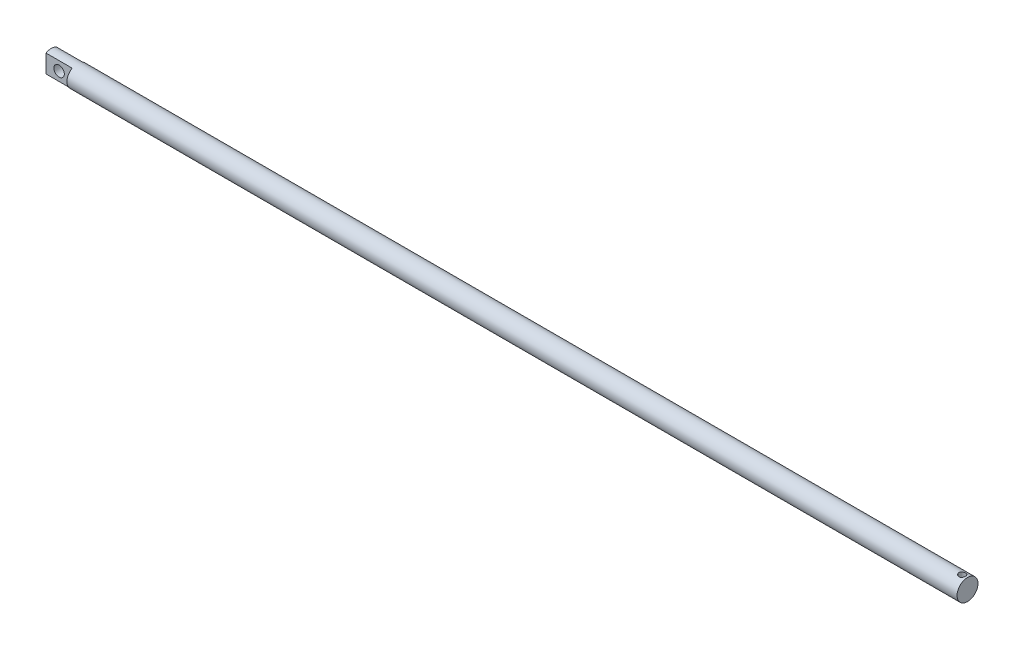
from build123d import *

# Parameters (mm, degrees)
SKETCH_1_R               = 8
EXTRUDE_1_DEPTH          = 700
SKETCH_2_R               = 4
CUT_EXTRUDE_1_DEPTH      = 9
CUT_EXTRUDE_1_DEPTH_BACK = 9
SKETCH_3_OUTSIDE_W       = 158.074
SKETCH_3_OUTSIDE_H       = 158.074
SKETCH_3_OUTSIDE_W_2     = 8
SKETCH_3_OUTSIDE_H_2     = 20
CUT_EXTRUDE_2_DEPTH      = 20
SKETCH_4_R               = 2.5
CUT_EXTRUDE_3_DEPTH      = 10


with BuildPart() as part:
    # 草图1 → 凸台-拉伸1 (new body)
    with BuildSketch(Plane(origin=(0, 0, 0), x_dir=(0, 0, -1), z_dir=(1, 0, 0))):
        Circle(SKETCH_1_R)
    extrude(amount=EXTRUDE_1_DEPTH)

    # 草图2 → 切除-拉伸1 (cut, two sides)
    with BuildSketch(Plane.XY) as cut_extrude_1_sk:
        with Locations((10, 0)):
            Circle(SKETCH_2_R)
    extrude(amount=CUT_EXTRUDE_1_DEPTH, mode=Mode.SUBTRACT)
    extrude(cut_extrude_1_sk.sketch, amount=-CUT_EXTRUDE_1_DEPTH_BACK, mode=Mode.SUBTRACT)

    # 草图3 outside → 切除-拉伸2 (cut)
    with BuildSketch(Plane.ZY):
        Rectangle(SKETCH_3_OUTSIDE_W, SKETCH_3_OUTSIDE_H)
        Rectangle(SKETCH_3_OUTSIDE_W_2, SKETCH_3_OUTSIDE_H_2, mode=Mode.SUBTRACT)
    extrude(amount=-CUT_EXTRUDE_2_DEPTH, mode=Mode.SUBTRACT)

    # 草图4 → 切除-拉伸3 (cut, symmetric)
    with BuildSketch(Plane(origin=(0, 0, 0), x_dir=(1, 0, 0), z_dir=(0, 1, 0))):
        with Locations((696, 0)):
            Circle(SKETCH_4_R)
    extrude(amount=CUT_EXTRUDE_3_DEPTH, both=True, mode=Mode.SUBTRACT)


solid = part.part
